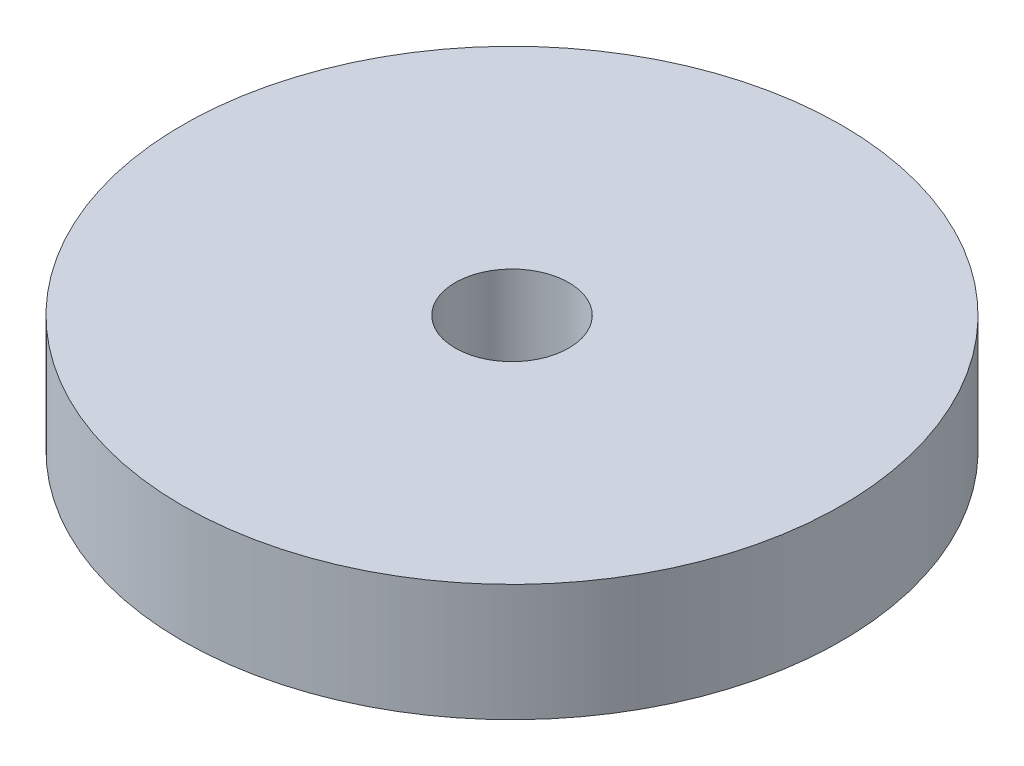
from build123d import *

# Parameters (mm, degrees)
SKETCH1_R           = 250
SKETCH1_R_2         = 43.075
BOSS_EXTRUDE1_DEPTH = 88.9


with BuildPart() as part:
    # Sketch1 → Boss-Extrude1 (new body)
    with BuildSketch(Plane(origin=(0, 0, 0), x_dir=(1, 0, 0), z_dir=(0, 1, 0))):
        Circle(SKETCH1_R)
        Circle(SKETCH1_R_2, mode=Mode.SUBTRACT)
    extrude(amount=BOSS_EXTRUDE1_DEPTH)


solid = part.part
